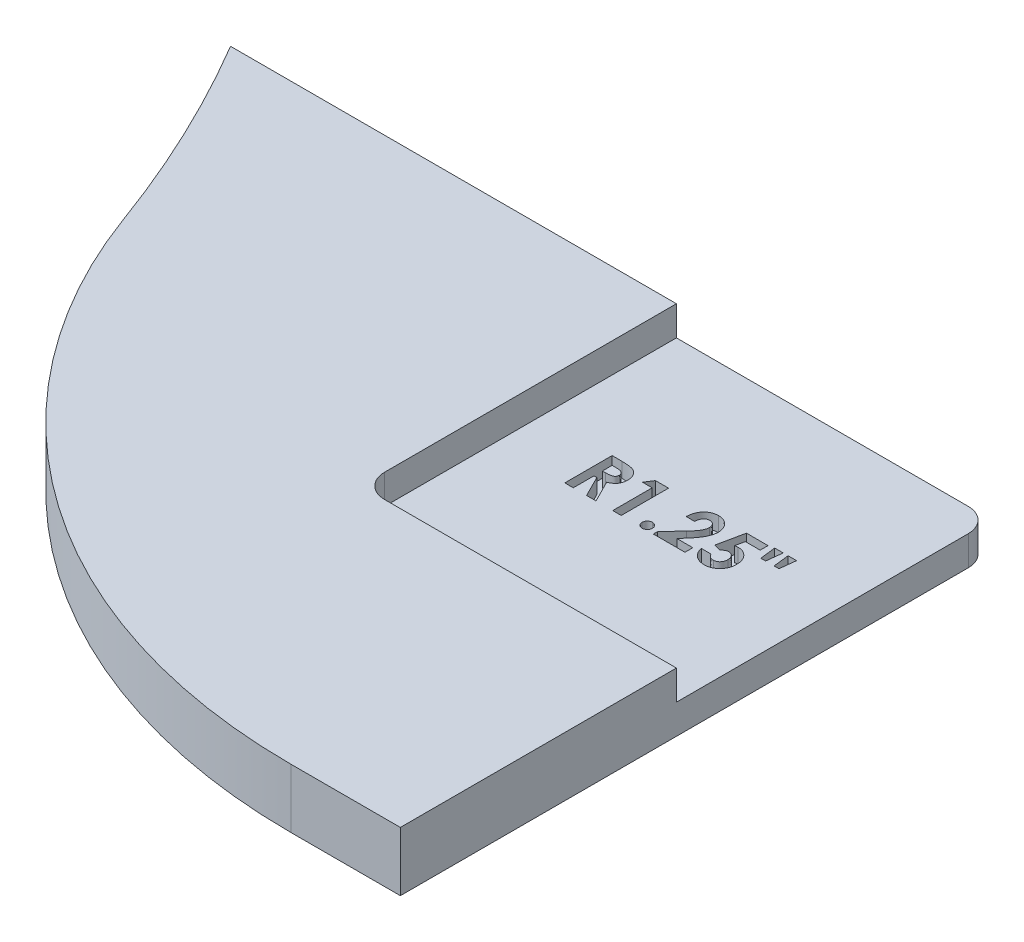
from build123d import *

# Parameters (mm, degrees)
BOSS_EXTRUDE1_DEPTH = 1.5875
FILLET1_R           = 31.75
SKETCH3_W           = 16.933333333
SKETCH3_H           = 16.933333333
CUT_EXTRUDE1_DEPTH  = 1.5875
CUT_EXTRUDE2_DEPTH  = 0.79375
FILLET2_R           = 1.27


with BuildPart() as part:
    # Sketch2 → Boss-Extrude1 (new, symmetric)
    with BuildSketch(Plane(origin=(0, 0, 0), x_dir=(1, 0, 0), z_dir=(0, 1, 0))):
        with BuildLine():
            Line((65.385731385, 1.5875), (97.135731385, 1.5875))
            Line((97.135731385, 1.5875), (97.135731385, 33.3375))
            Line((97.135731385, 33.3375), (56.270997137, 33.3375))
            ThreePointArc((56.270997137, 33.3375), (62.865773865, 18.047395972), (65.385731385, 1.5875))
        make_face()
    extrude(amount=BOSS_EXTRUDE1_DEPTH, both=True)

    # Fillet1
    fillet1_edges = [part.edges().sort_by_distance(p)[0] for p in [
        (65.385731385, 0, -1.5875),
    ]]
    fillet(fillet1_edges, radius=FILLET1_R)

    # Sketch3 → Cut-Extrude1 (cut)
    with BuildSketch(Plane(origin=(0, 1.5875, 0), x_dir=(1, 0, 0), z_dir=(0, 1, 0))):
        with Locations((88.669064719, 24.870833334)):
            Rectangle(SKETCH3_W, SKETCH3_H)
    extrude(amount=-CUT_EXTRUDE1_DEPTH, mode=Mode.SUBTRACT)

    # Sketch4 → Cut-Extrude2 (cut)
    with BuildSketch(Plane(origin=(0, 0, 0), x_dir=(1, 0, 0), z_dir=(0, 1, 0))):
        with BuildLine():
            Line((83.947269847, 26.140833333), (84.47847177, 26.140833333))
            add(Edge.make_bspline(
                [(84.47847177, 26.140833333), (84.513584055, 26.140708705), (84.58111487, 26.140469009), (84.678490618, 26.136687247), (84.767943633, 26.131424614), (84.84960636, 26.123393697), (84.923443861, 26.112745672), (84.989530139, 26.100193413), (85.047863263, 26.085887422), (85.098935191, 26.068061028), (85.145025081, 26.047953127), (85.187987265, 26.024848779), (85.228769555, 25.99900526), (85.267099364, 25.969742555), (85.303309788, 25.937587095), (85.337469139, 25.902506512), (85.369094715, 25.864203335), (85.397990687, 25.822919594), (85.424327041, 25.779490045), (85.447602853, 25.733855059), (85.466530783, 25.6859829), (85.483255637, 25.636565425), (85.495302008, 25.584896199), (85.503680083, 25.531478234), (85.509814182, 25.47612349), (85.510166863, 25.438517935), (85.51034677, 25.419334936)],
                knots=[0, 0, 0, 0, 1.749336639, 3.364467119, 4.854658419, 6.213483162, 7.451590619, 8.570285859, 9.5643256, 10.440900261, 11.26203566, 12.067320669, 12.869050712, 13.665104639, 14.467235401, 15.27997916, 16.102287765, 16.939272006, 17.78853747, 18.631303466, 19.488103222, 20.351255419, 21.228522269, 22.127379805, 23.044756219, 24, 24, 24, 24], degree=3))
            add(Edge.make_bspline(
                [(85.51034677, 25.419334936), (85.509879437, 25.399312291), (85.508963083, 25.360051534), (85.504027102, 25.302380684), (85.49500568, 25.247205248), (85.481341423, 25.194686774), (85.465636134, 25.144171608), (85.444752129, 25.096591786), (85.421182465, 25.051255329), (85.393189464, 25.008803538), (85.362468512, 24.968293474), (85.326740692, 24.931277228), (85.288320617, 24.895765316), (85.245048555, 24.863982085), (85.198831978, 24.833778467), (85.148752612, 24.806405945), (85.095137292, 24.781176438), (85.057443067, 24.767106723), (85.038167282, 24.759911859)],
                knots=[0, 0, 0, 0, 1.099860209, 2.156625411, 3.176576793, 4.16617041, 5.135385252, 6.078461593, 7.016046972, 7.938469504, 8.868247731, 9.803980173, 10.76021508, 11.73834243, 12.748633912, 13.790971185, 14.870363756, 16, 16, 16, 16], degree=3))
            Line((85.038167282, 24.759911859), (85.624321129, 23.600833333))
            Line((85.624321129, 23.600833333), (85.117542282, 23.600833333))
            Line((85.117542282, 23.600833333), (84.55784677, 24.708012821))
            Line((84.55784677, 24.708012821), (84.403167282, 24.708012821))
            Line((84.403167282, 24.708012821), (84.403167282, 23.600833333))
            Line((84.403167282, 23.600833333), (83.947269847, 23.600833333))
            Line((83.947269847, 23.600833333), (83.947269847, 26.140833333))
        make_face()
        with BuildLine():
            Line((84.403167282, 25.163910256), (84.580743404, 25.163910256))
            add(Edge.make_bspline(
                [(84.580743404, 25.163910256), (84.602453561, 25.164154771), (84.644023847, 25.164622963), (84.703807378, 25.166794634), (84.758105081, 25.172027288), (84.80715013, 25.17863855), (84.851189315, 25.186272207), (84.889829821, 25.197211702), (84.92366704, 25.208933647), (84.9523, 25.223500984), (84.976763343, 25.240067205), (84.997885874, 25.258886845), (85.015357236, 25.280668181), (85.029737058, 25.304819292), (85.040922996, 25.331553787), (85.049087873, 25.360578183), (85.053650833, 25.392223104), (85.054175817, 25.414062409), (85.054449334, 25.425440705)],
                knots=[0, 0, 0, 0, 1.688639943, 3.233382647, 4.650958383, 5.928841754, 7.082724185, 8.122798841, 9.049171256, 9.863274652, 10.613301712, 11.341792392, 12.054588806, 12.776240173, 13.521029143, 14.301969904, 15.115324896, 16, 16, 16, 16], degree=3))
            add(Edge.make_bspline(
                [(85.054449334, 25.425440705), (85.053932225, 25.43890206), (85.052916459, 25.465344397), (85.042836914, 25.503412091), (85.026792455, 25.538646346), (85.004799896, 25.570887966), (84.977103127, 25.599153195), (84.9453189, 25.62406922), (84.908761233, 25.643770948), (84.874911585, 25.656765998), (84.844116317, 25.66454107), (84.81632456, 25.670334985), (84.784141537, 25.674441299), (84.747542953, 25.678796776), (84.706622099, 25.681621083), (84.661155931, 25.683682263), (84.611275028, 25.684525594), (84.576503301, 25.684795192), (84.558355584, 25.684935897)],
                knots=[0, 0, 0, 0, 1.020303359, 2.004196876, 2.966617323, 3.9489082, 4.950758222, 5.960522915, 7.003732012, 8.091992268, 8.70421221, 9.413913587, 10.24622431, 11.166358409, 12.212345909, 13.359657661, 14.621978493, 16, 16, 16, 16], degree=3))
            Line((84.558355584, 25.684935897), (84.403167282, 25.684935897))
            Line((84.403167282, 25.684935897), (84.403167282, 25.163910256))
        make_face(mode=Mode.SUBTRACT)
        Polygon((86.271023853, 26.140833333), (86.975731385, 26.140833333), (86.975731385, 23.600833333), (86.519833949, 23.600833333), (86.519833949, 25.7175), (85.998808308, 25.7175), align=None)
        with BuildLine():
            add(Edge.make_bspline(
                [(88.131757026, 24.121858974), (88.150161065, 24.120849925), (88.186395439, 24.118863281), (88.238749169, 24.104037168), (88.285998712, 24.077399942), (88.328246117, 24.042656297), (88.363969458, 24.000855054), (88.389789482, 23.953185847), (88.405868258, 23.901033843), (88.407643366, 23.864685471), (88.408551898, 23.846081731)],
                knots=[0, 0, 0, 0, 1.016957001, 2.002212695, 2.9757545, 3.99499976, 5.013036768, 5.994806404, 6.97370641, 8, 8, 8, 8], degree=3))
            add(Edge.make_bspline(
                [(88.408551898, 23.846081731), (88.407649318, 23.827475003), (88.405885838, 23.791120793), (88.389678218, 23.738867167), (88.364008042, 23.690806163), (88.328243251, 23.648556992), (88.286173673, 23.613158571), (88.238640534, 23.586766979), (88.186495172, 23.571099817), (88.150178619, 23.569221837), (88.131757026, 23.568269231)],
                knots=[0, 0, 0, 0, 1.023218912, 1.999186227, 2.986238111, 4.008388923, 5.030539734, 6.0011649, 6.986089706, 8, 8, 8, 8], degree=3))
            add(Edge.make_bspline(
                [(88.131757026, 23.568269231), (88.113331068, 23.569214091), (88.07700591, 23.5710768), (88.024779491, 23.586899038), (87.976895426, 23.61298237), (87.934815278, 23.64859993), (87.898890706, 23.690656555), (87.873950356, 23.739018808), (87.857591767, 23.791101093), (87.855852395, 23.827468333), (87.854962154, 23.846081731)],
                knots=[0, 0, 0, 0, 1.013427518, 1.99788335, 2.976245624, 3.997909735, 5.019573847, 6.001765691, 6.977268297, 8, 8, 8, 8], degree=3))
            add(Edge.make_bspline(
                [(87.854962154, 23.846081731), (87.855858269, 23.864692257), (87.857609115, 23.901053886), (87.87383941, 23.953032459), (87.898930677, 24.001005475), (87.934812282, 24.04261327), (87.977071288, 24.077574767), (88.024670247, 24.103906918), (88.077105592, 24.118886469), (88.113348601, 24.120857735), (88.131757026, 24.121858974)],
                knots=[0, 0, 0, 0, 1.025808215, 2.00424526, 2.981110158, 3.998665696, 5.017428914, 5.998734231, 6.983523959, 8, 8, 8, 8], degree=3))
        make_face()
        with BuildLine():
            Line((89.222654462, 25.294166667), (88.766757026, 25.294166667))
            add(Edge.make_bspline(
                [(88.766757026, 25.294166667), (88.768725977, 25.328652896), (88.772573189, 25.396036917), (88.787876427, 25.493914365), (88.808382241, 25.586397791), (88.835749971, 25.673163677), (88.870139316, 25.754180495), (88.910665347, 25.829724436), (88.958363413, 25.89939776), (89.012218343, 25.962864462), (89.071315828, 26.019801026), (89.134428946, 26.070284561), (89.202523097, 26.111942303), (89.274354146, 26.146222768), (89.34990986, 26.173611267), (89.429905117, 26.191922695), (89.513647273, 26.204323373), (89.57097556, 26.205408482), (89.600194526, 26.205961538)],
                knots=[0, 0, 0, 0, 1.199038563, 2.342849363, 3.436047546, 4.486744587, 5.497670872, 6.488682221, 7.459191391, 8.424610317, 9.374430501, 10.305433194, 11.225809216, 12.140057399, 13.06607119, 14.010487599, 14.985989317, 16, 16, 16, 16], degree=3))
            add(Edge.make_bspline(
                [(89.600194526, 26.205961538), (89.636060392, 26.204842429), (89.706078969, 26.202657665), (89.807821514, 26.184020901), (89.902837927, 26.152848034), (89.99105914, 26.109291319), (90.07173411, 26.053957077), (90.14484946, 25.987980049), (90.208194063, 25.909976004), (90.262169544, 25.823190562), (90.307016718, 25.731296992), (90.338443749, 25.636275231), (90.359100399, 25.540646769), (90.361303558, 25.476255404), (90.362398052, 25.444266827)],
                knots=[0, 0, 0, 0, 1.075374347, 2.099382735, 3.09057751, 4.06680945, 5.040638231, 6.016817125, 7.011024321, 8.044445721, 9.0776792, 10.070479129, 11.0414456, 12, 12, 12, 12], degree=3))
            add(Edge.make_bspline(
                [(90.362398052, 25.444266827), (90.361971914, 25.424917875), (90.361114203, 25.385973213), (90.355150428, 25.327040383), (90.346203586, 25.267010404), (90.332713929, 25.205934749), (90.315891222, 25.143796295), (90.295482845, 25.080409084), (90.271015409, 25.016132499), (90.242897223, 24.950243118), (90.209352156, 24.882527022), (90.170293589, 24.811969123), (90.124684818, 24.738632009), (90.07307674, 24.662101597), (90.015218706, 24.582498586), (89.950828274, 24.500062765), (89.880647069, 24.414503657), (89.830837494, 24.357312195), (89.805246609, 24.327928686)],
                knots=[0, 0, 0, 0, 0.728284026, 1.46585585, 2.227944881, 3.01186502, 3.81876927, 4.650621989, 5.517437689, 6.406905708, 7.346299482, 8.360816762, 9.441613733, 10.596154504, 11.834900912, 13.145207542, 14.533280747, 16, 16, 16, 16], degree=3))
            Line((89.805246609, 24.327928686), (89.540154462, 24.024166667))
            Line((89.540154462, 24.024166667), (90.394962154, 24.024166667))
            Line((90.394962154, 24.024166667), (90.394962154, 23.600833333))
            Line((90.394962154, 23.600833333), (88.701628821, 23.600833333))
            Line((88.701628821, 23.600833333), (88.701628821, 23.831834936))
            Line((88.701628821, 23.831834936), (89.453656064, 24.632199519))
            add(Edge.make_bspline(
                [(89.453656064, 24.632199519), (89.475429186, 24.655546403), (89.517597265, 24.700762392), (89.577598095, 24.767166883), (89.631893547, 24.83018316), (89.679357759, 24.890482219), (89.722481593, 24.946108205), (89.759342159, 24.998737752), (89.790276704, 25.047895073), (89.823860539, 25.107170216), (89.855754144, 25.177866372), (89.885018456, 25.259311243), (89.902857079, 25.337153782), (89.905319373, 25.387877653), (89.906500616, 25.412211538)],
                knots=[0, 0, 0, 0, 1.246127091, 2.413378631, 3.493388633, 4.492180848, 5.408488754, 6.240484944, 6.999099869, 7.674939598, 8.898438119, 10.020720584, 11.050475521, 12, 12, 12, 12], degree=3))
            add(Edge.make_bspline(
                [(89.906500616, 25.412211538), (89.905617429, 25.435752695), (89.903906114, 25.48136746), (89.885100148, 25.54625422), (89.855965292, 25.605002558), (89.814910166, 25.655857006), (89.76517955, 25.697647479), (89.707711152, 25.728730058), (89.642973508, 25.746664564), (89.597591186, 25.748909323), (89.574245007, 25.750064103)],
                knots=[0, 0, 0, 0, 1.062038974, 2.057870785, 3.028805853, 4.01125022, 4.991535629, 5.949134679, 6.94496649, 8, 8, 8, 8], degree=3))
            add(Edge.make_bspline(
                [(89.574245007, 25.750064103), (89.562184073, 25.749637513), (89.538440188, 25.748797704), (89.503538533, 25.74320732), (89.4703271, 25.733354852), (89.438436229, 25.720153931), (89.408206266, 25.702656016), (89.379713462, 25.681087048), (89.352657609, 25.655995143), (89.327162795, 25.62745876), (89.303959186, 25.595612149), (89.283349826, 25.560746163), (89.266309316, 25.522882445), (89.251306231, 25.482520852), (89.239735135, 25.439227869), (89.231309941, 25.3932626), (89.224904828, 25.344699824), (89.22341823, 25.311317481), (89.222654462, 25.294166667)],
                knots=[0, 0, 0, 0, 0.903469896, 1.778625579, 2.63899355, 3.493148037, 4.358286772, 5.247621495, 6.164656832, 7.118446693, 8.109501108, 9.111810964, 10.146451449, 11.215617525, 12.33435995, 13.498009769, 14.714554818, 16, 16, 16, 16], degree=3))
        make_face()
        with BuildLine():
            Line((91.15970975, 26.140833333), (92.316244206, 26.140833333))
            Line((92.316244206, 26.140833333), (92.316244206, 25.7175))
            Line((92.316244206, 25.7175), (91.520967763, 25.7175))
            Line((91.520967763, 25.7175), (91.421749013, 25.237179487))
            add(Edge.make_bspline(
                [(91.421749013, 25.237179487), (91.435268988, 25.240944971), (91.461933157, 25.248371278), (91.50210276, 25.255818925), (91.541032703, 25.260646253), (91.566578294, 25.261290154), (91.578972571, 25.261602564)],
                knots=[0, 0, 0, 0, 1.05461699, 2.079921384, 3.068411212, 4, 4, 4, 4], degree=3))
            add(Edge.make_bspline(
                [(91.578972571, 25.261602564), (91.605980999, 25.260983682), (91.65922056, 25.259763728), (91.737103283, 25.248182388), (91.81168059, 25.229942129), (91.882724268, 25.203927756), (91.950164916, 25.170069377), (92.014084286, 25.129110231), (92.074560828, 25.080978377), (92.130520223, 25.025643681), (92.181938053, 24.964884932), (92.226642924, 24.899167915), (92.264823673, 24.829429693), (92.295191321, 24.755236773), (92.319160058, 24.677055137), (92.336480402, 24.594834683), (92.346722787, 24.508477969), (92.34810391, 24.449562957), (92.348808308, 24.419515224)],
                knots=[0, 0, 0, 0, 1.01440847, 1.999622559, 2.951875003, 3.895578053, 4.836219714, 5.782137149, 6.743708247, 7.735272588, 8.734977101, 9.730283169, 10.717124674, 11.717316708, 12.737475749, 13.78628267, 14.87096371, 16, 16, 16, 16], degree=3))
            add(Edge.make_bspline(
                [(92.348808308, 24.419515224), (92.347947523, 24.38912638), (92.346248941, 24.329160308), (92.335167254, 24.24098897), (92.315607876, 24.156540734), (92.288741114, 24.075589532), (92.253345875, 23.998730338), (92.210778256, 23.925166947), (92.160318553, 23.855445397), (92.102461948, 23.790280418), (92.03956423, 23.730718377), (91.972593008, 23.678321535), (91.902018774, 23.634230017), (91.827839826, 23.598596616), (91.750481753, 23.570404103), (91.669921074, 23.5498813), (91.585766276, 23.538112612), (91.528636103, 23.536516441), (91.499597571, 23.535705128)],
                knots=[0, 0, 0, 0, 1.06808661, 2.107647099, 3.116961351, 4.110378221, 5.100014249, 6.085620622, 7.093190682, 8.119403071, 9.144090782, 10.133780668, 11.103064255, 12.062861538, 13.020824475, 13.992378307, 14.979551724, 16, 16, 16, 16], degree=3))
            add(Edge.make_bspline(
                [(91.499597571, 23.535705128), (91.473629276, 23.536368833), (91.422414364, 23.537677798), (91.346977047, 23.545723384), (91.274247096, 23.559948055), (91.204610629, 23.580534838), (91.137334951, 23.605872468), (91.073197791, 23.637561963), (91.011846703, 23.674999911), (90.953455901, 23.71750307), (90.898974152, 23.765381231), (90.849248985, 23.817792126), (90.803979357, 23.874075143), (90.764133967, 23.934924643), (90.729837718, 24.000250725), (90.699423105, 24.069283505), (90.67452844, 24.142743905), (90.661895114, 24.193670736), (90.655474975, 24.219551282)],
                knots=[0, 0, 0, 0, 1.054957082, 2.080596141, 3.077793124, 4.061112343, 5.027190972, 5.994718051, 6.962465889, 7.943658696, 8.924948258, 9.904494768, 10.875059, 11.855380583, 12.854004648, 13.869083016, 14.917087635, 16, 16, 16, 16], degree=3))
            Line((90.655474975, 24.219551282), (91.176500616, 24.219551282))
            add(Edge.make_bspline(
                [(91.176500616, 24.219551282), (91.186024977, 24.201617118), (91.204534486, 24.166764116), (91.239743665, 24.120491519), (91.279158105, 24.081032236), (91.322422267, 24.048000741), (91.369816476, 24.023254108), (91.419409507, 24.004487406), (91.471824376, 23.993642824), (91.507521217, 23.992287144), (91.52554709, 23.991602564)],
                knots=[0, 0, 0, 0, 1.104910296, 2.147267069, 3.153527244, 4.136738762, 5.099945312, 6.05603338, 7.018353, 8, 8, 8, 8], degree=3))
            add(Edge.make_bspline(
                [(91.52554709, 23.991602564), (91.538110882, 23.992075272), (91.562830354, 23.993005333), (91.599250588, 23.997925589), (91.634015301, 24.007244443), (91.667382961, 24.020148889), (91.699443202, 24.036242191), (91.729736428, 24.056558936), (91.758789689, 24.079944262), (91.786160674, 24.106779004), (91.810950898, 24.136693499), (91.832689213, 24.168838663), (91.852126264, 24.202500223), (91.866523584, 24.2390116), (91.878313773, 24.277282549), (91.886996544, 24.31760176), (91.89218548, 24.360016324), (91.892665836, 24.388971558), (91.892910872, 24.403741987)],
                knots=[0, 0, 0, 0, 0.978869489, 1.925942215, 2.855067702, 3.774946051, 4.70828698, 5.642468714, 6.60995405, 7.609372294, 8.622401667, 9.629904756, 10.629323, 11.642352373, 12.678539694, 13.745912462, 14.850161547, 16, 16, 16, 16], degree=3))
            add(Edge.make_bspline(
                [(91.892910872, 24.403741987), (91.89262648, 24.418169561), (91.892072903, 24.446253185), (91.887493603, 24.487490004), (91.879301324, 24.526616282), (91.868139273, 24.563931698), (91.853850516, 24.599209654), (91.836388699, 24.632660141), (91.815679224, 24.66411408), (91.791610907, 24.6929311), (91.765944701, 24.719362889), (91.738370948, 24.742479922), (91.709138074, 24.761665454), (91.679154454, 24.778414982), (91.647223249, 24.790604923), (91.614062465, 24.798999686), (91.579706974, 24.805159425), (91.556273839, 24.805521332), (91.544373212, 24.805705128)],
                knots=[0, 0, 0, 0, 1.166249705, 2.270133367, 3.348514167, 4.393962215, 5.415026464, 6.420877785, 7.440098956, 8.453121383, 9.451844239, 10.415694839, 11.355045125, 12.27538808, 13.187007209, 14.108269027, 15.039275622, 16, 16, 16, 16], degree=3))
            add(Edge.make_bspline(
                [(91.544373212, 24.805705128), (91.531446365, 24.805214626), (91.505538192, 24.804231555), (91.46704513, 24.796232567), (91.429016188, 24.783287203), (91.391239886, 24.765427023), (91.354091217, 24.742053682), (91.316589812, 24.714639432), (91.279990922, 24.68119237), (91.25672033, 24.656280922), (91.244681706, 24.643393429)],
                knots=[0, 0, 0, 0, 0.88288272, 1.769486374, 2.674910571, 3.623812639, 4.617874466, 5.670434592, 6.794841017, 8, 8, 8, 8], degree=3))
            Line((91.244681706, 24.643393429), (90.861035872, 24.731418269))
            Line((90.861035872, 24.731418269), (91.15970975, 26.140833333))
        make_face()
        Polygon((93.683936513, 25.359294872), (93.423423693, 25.359294872), (93.325731385, 26.205961538), (93.781628821, 26.205961538), align=None)
        Polygon((92.967526257, 25.359294872), (92.707013436, 25.359294872), (92.609321129, 26.205961538), (93.065218564, 26.205961538), align=None)
    extrude(amount=-CUT_EXTRUDE2_DEPTH, mode=Mode.SUBTRACT)

    # Fillet2
    fillet2_edges = [part.edges().sort_by_distance(p)[0] for p in [
        (97.135731385, -0.79375, -33.3375),
        (80.202398052, 0.79375, -16.404166667),
    ]]
    fillet(fillet2_edges, radius=FILLET2_R)


solid = part.part
